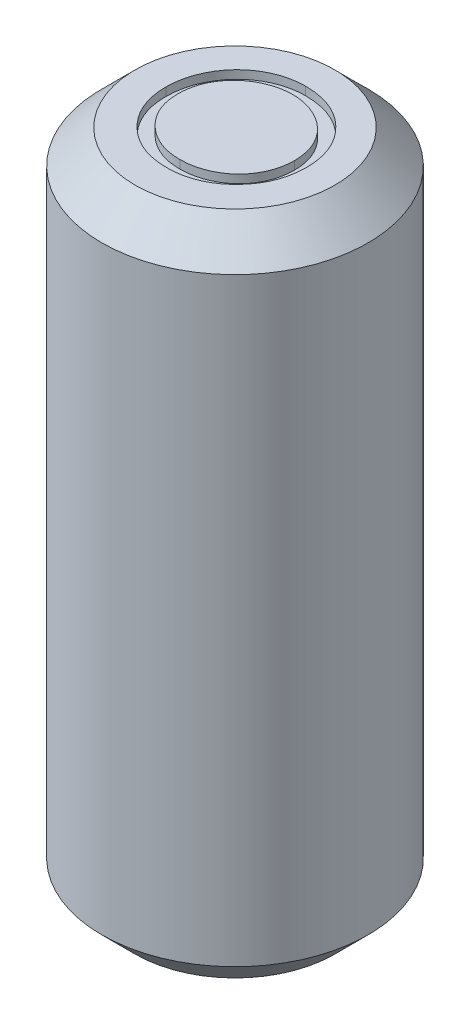
from build123d import *

# Parameters (mm, degrees)
CROQUIS1_R              = 4
SALIENTE_EXTRUIR1_DEPTH = 20
CHAFL_N1_SIZE           = 1
CORTAR_EXTRUIR2_DEPTH   = 0.25


with BuildPart() as part:
    # Croquis1 → Saliente-Extruir1 (new body)
    with BuildSketch(Plane(origin=(0, 0, 0), x_dir=(1, 0, 0), z_dir=(0, 1, 0))):
        Circle(CROQUIS1_R)
    extrude(amount=SALIENTE_EXTRUIR1_DEPTH)

    # Chaflán1
    chafl_n1_edges = [part.edges().sort_by_distance(p)[0] for p in [
        (-4, 0, 0),
        (-4, 20, 0),
    ]]
    chamfer(chafl_n1_edges, length=CHAFL_N1_SIZE)

    # Croquis4 → Cortar-Extruir2 (cut)
    with BuildSketch(Plane(origin=(0, 20, 0), x_dir=(1, 0, 0), z_dir=(0, 1, 0))):
        with BuildLine():
            add(Edge.make_bspline(
                [(-0.015518725, 2.134649306), (0.058547681, 2.13277333), (0.204020215, 2.129088757), (0.417820098, 2.100884068), (0.621928779, 2.052089336), (0.818008937, 1.98710307), (1.003715196, 1.900412344), (1.180445359, 1.795629318), (1.347778929, 1.671656222), (1.503460508, 1.529451391), (1.645925594, 1.374727444), (1.771440893, 1.209609832), (1.876632085, 1.035096915), (1.963015842, 0.851713109), (2.030785682, 0.659873146), (2.077550303, 0.458554285), (2.107422475, 0.249060925), (2.110914792, 0.10617308), (2.112686403, 0.033687768)],
                knots=[0, 0, 0, 0, 0.000222163, 0.000436347, 0.000645474, 0.000850973, 0.001054962, 0.001259031, 0.001466406, 0.001678557, 0.001890656, 0.002096587, 0.002299693, 0.002500778, 0.002703768, 0.002908812, 0.003119927, 0.003337287, 0.003337287, 0.003337287, 0.003337287], degree=3))
            add(Edge.make_bspline(
                [(2.112686403, 0.033687768), (2.110915051, -0.0382636), (2.107423512, -0.18008808), (2.077516338, -0.388252016), (2.030612338, -0.588355669), (1.963645177, -0.780064987), (1.877673201, -0.963582203), (1.771781577, -1.138424436), (1.647048765, -1.304649005), (1.505098078, -1.460434908), (1.35035403, -1.60328916), (1.184376582, -1.727767875), (1.010898502, -1.834881161), (0.827687407, -1.920348217), (0.63717308, -1.988658983), (0.437650425, -2.035233417), (0.230054363, -2.065275752), (0.088487501, -2.068725485), (0.016532557, -2.070478899)],
                knots=[0, 0, 0, 0, 0.000215759, 0.000425286, 0.000629551, 0.00083152, 0.00103333, 0.001236435, 0.001443647, 0.001655798, 0.001867897, 0.002074468, 0.002277305, 0.00247839, 0.002679869, 0.002883353, 0.003092087, 0.003307846, 0.003307846, 0.003307846, 0.003307846], degree=3))
            add(Edge.make_bspline(
                [(0.016532557, -2.070478899), (-0.055952379, -2.068708171), (-0.198839483, -2.065217595), (-0.408596095, -2.03529599), (-0.610056374, -1.988505928), (-0.802644204, -1.921638001), (-0.98646698, -1.835218309), (-1.161884218, -1.729841876), (-1.328191815, -1.604805143), (-1.484010953, -1.462900486), (-1.626581466, -1.308418712), (-1.750877895, -1.142893849), (-1.856278024, -0.969573328), (-1.942407547, -0.787976157), (-2.010595501, -0.598980223), (-2.057115293, -0.40132482), (-2.087213524, -0.196136813), (-2.09068192, -0.056430644), (-2.092441802, 0.014456999)],
                knots=[0, 0, 0, 0, 0.00021736, 0.000428475, 0.000634298, 0.000837024, 0.001038834, 0.001242626, 0.001449838, 0.001661989, 0.001874088, 0.002079537, 0.002281957, 0.002481593, 0.002681563, 0.002883489, 0.003089842, 0.003302399, 0.003302399, 0.003302399, 0.003302399], degree=3))
            add(Edge.make_bspline(
                [(-2.092441802, 0.014456999), (-2.09183079, 0.062037192), (-2.090616474, 0.156597333), (-2.075997397, 0.297016305), (-2.054784025, 0.435177056), (-2.024381839, 0.570686711), (-1.984619934, 0.703213551), (-1.937703331, 0.833671565), (-1.88040065, 0.960738678), (-1.815622767, 1.08501684), (-1.743323558, 1.204568733), (-1.663465558, 1.317573971), (-1.578853709, 1.424980824), (-1.486095545, 1.524005971), (-1.388248179, 1.61753015), (-1.283724318, 1.704116112), (-1.173161753, 1.784544628), (-1.056084748, 1.857025017), (-0.935378148, 1.922578314), (-0.810947544, 1.978831858), (-0.684482891, 2.027113071), (-0.555391865, 2.066245443), (-0.424017268, 2.097139198), (-0.290072372, 2.118176174), (-0.153663885, 2.132832537), (-0.061765234, 2.134041111), (-0.015518725, 2.134649306)],
                knots=[0, 0, 0, 0, 0.000142684, 0.000283569, 0.000423077, 0.000561875, 0.000699793, 0.000837942, 0.000977471, 0.001117606, 0.001258187, 0.001396235, 0.001532512, 0.001668024, 0.001802915, 0.001938339, 0.002074896, 0.002212747, 0.002351135, 0.002486682, 0.002622105, 0.002756954, 0.002891065, 0.003026617, 0.003163515, 0.003302194, 0.003302194, 0.003302194, 0.003302194], degree=3))
        make_face()
        with BuildLine():
            add(Edge.make_bspline(
                [(0.00210948, 1.724392896), (-0.035850101, 1.723930164), (-0.111406368, 1.723009125), (-0.223731552, 1.710876878), (-0.334579476, 1.693585577), (-0.443973033, 1.668920981), (-0.551454507, 1.63531635), (-0.658025754, 1.596641026), (-0.762714958, 1.549531208), (-0.86517651, 1.49630526), (-0.964508024, 1.437392208), (-1.058236826, 1.372281617), (-1.146605562, 1.302500412), (-1.229397867, 1.227885741), (-1.306370635, 1.148057625), (-1.379038865, 1.064226269), (-1.444489816, 0.973995536), (-1.504473332, 0.879812214), (-1.558150864, 0.781798979), (-1.605882698, 0.680987707), (-1.644927279, 0.576556065), (-1.676769995, 0.469637028), (-1.703169779, 0.360399931), (-1.719894263, 0.248016104), (-1.732159817, 0.133050262), (-1.733028212, 0.055356714), (-1.733467443, 0.016059563)],
                knots=[0, 0, 0, 0, 0.000113827, 0.000226566, 0.000338539, 0.000450309, 0.000562594, 0.000676167, 0.000790231, 0.000906707, 0.001022414, 0.001136438, 0.001248815, 0.001360011, 0.00147051, 0.001581322, 0.001692547, 0.001804581, 0.001916109, 0.00202759, 0.002138911, 0.002250197, 0.002362147, 0.002475703, 0.002590835, 0.002708667, 0.002708667, 0.002708667, 0.002708667], degree=3))
            add(Edge.make_bspline(
                [(-1.733467443, 0.016059563), (-1.732010458, -0.041725833), (-1.729144118, -0.155407581), (-1.704049752, -0.321999746), (-1.665396067, -0.482100645), (-1.608416219, -0.634834255), (-1.537158374, -0.781513436), (-1.449127642, -0.920836984), (-1.344831545, -1.052842554), (-1.226358943, -1.176608576), (-1.096847278, -1.28957521), (-0.959324158, -1.388733391), (-0.815262892, -1.472630819), (-0.664287804, -1.540979473), (-0.507204902, -1.595139174), (-0.343001986, -1.632257609), (-0.17277289, -1.656686701), (-0.056737855, -1.659032708), (0.00210948, -1.660222489)],
                knots=[0, 0, 0, 0, 0.000173262, 0.000340861, 0.0005043, 0.000666548, 0.000828884, 0.000992726, 0.001159918, 0.001332774, 0.001505994, 0.001674777, 0.001840658, 0.002005251, 0.002171224, 0.002338187, 0.002509641, 0.002686071, 0.002686071, 0.002686071, 0.002686071], degree=3))
            add(Edge.make_bspline(
                [(0.00210948, -1.660222489), (0.041663196, -1.659679055), (0.120110095, -1.658601263), (0.236790692, -1.647745632), (0.351369219, -1.630337782), (0.463684968, -1.605274175), (0.573610466, -1.573905939), (0.681604527, -1.536639965), (0.786516859, -1.49014716), (0.889670959, -1.438778073), (0.988409521, -1.380217893), (1.082667272, -1.31731715), (1.170068392, -1.247638727), (1.25279876, -1.174132655), (1.330087547, -1.095316829), (1.4014121, -1.011293718), (1.466532251, -0.921532967), (1.52649299, -0.827492504), (1.579982434, -0.729211072), (1.626587118, -0.628034297), (1.666125536, -0.524211315), (1.698043828, -0.417592376), (1.723055784, -0.308379978), (1.740289978, -0.196427888), (1.752345336, -0.081960068), (1.753253996, -0.004538519), (1.753712044, 0.03448905)],
                knots=[0, 0, 0, 0, 0.000118633, 0.000235285, 0.000351216, 0.000466113, 0.00058025, 0.000694035, 0.000808509, 0.000924255, 0.001039553, 0.001152673, 0.001263924, 0.001374585, 0.00148451, 0.001594802, 0.001704908, 0.001816941, 0.001929172, 0.002040317, 0.002150888, 0.002262174, 0.002373943, 0.002486708, 0.002601839, 0.00271887, 0.00271887, 0.00271887, 0.00271887], degree=3))
            add(Edge.make_bspline(
                [(1.753712044, 0.03448905), (1.753253629, 0.073249626), (1.752344279, 0.150138369), (1.740295736, 0.263807876), (1.723037576, 0.374954403), (1.69816591, 0.483141607), (1.666108591, 0.588397064), (1.626580213, 0.690621918), (1.579968443, 0.790196999), (1.526473329, 0.886876195), (1.466340959, 0.979647324), (1.400633253, 1.068335796), (1.328215712, 1.151276071), (1.251157398, 1.230515722), (1.167533529, 1.304364738), (1.077722907, 1.372847619), (0.982815847, 1.437617076), (0.882327578, 1.496046289), (0.778620202, 1.550005412), (0.67220425, 1.59623513), (0.564285279, 1.635517552), (0.455137722, 1.669022655), (0.34384289, 1.693488975), (0.2311528, 1.710892461), (0.117223361, 1.723004902), (0.040602539, 1.723928763), (0.00210948, 1.724392896)],
                knots=[0, 0, 0, 0, 0.00011623, 0.000230564, 0.000342537, 0.000453525, 0.000563278, 0.000672352, 0.000782043, 0.000892869, 0.001003554, 0.00111349, 0.001223695, 0.001333619, 0.001444879, 0.001558028, 0.00167226, 0.001789346, 0.001906533, 0.002022797, 0.002137122, 0.002250941, 0.002365055, 0.002478611, 0.002592945, 0.002708374, 0.002708374, 0.002708374, 0.002708374], degree=3))
        make_face(mode=Mode.SUBTRACT)
    extrude(amount=-CORTAR_EXTRUIR2_DEPTH, mode=Mode.SUBTRACT)


solid = part.part
